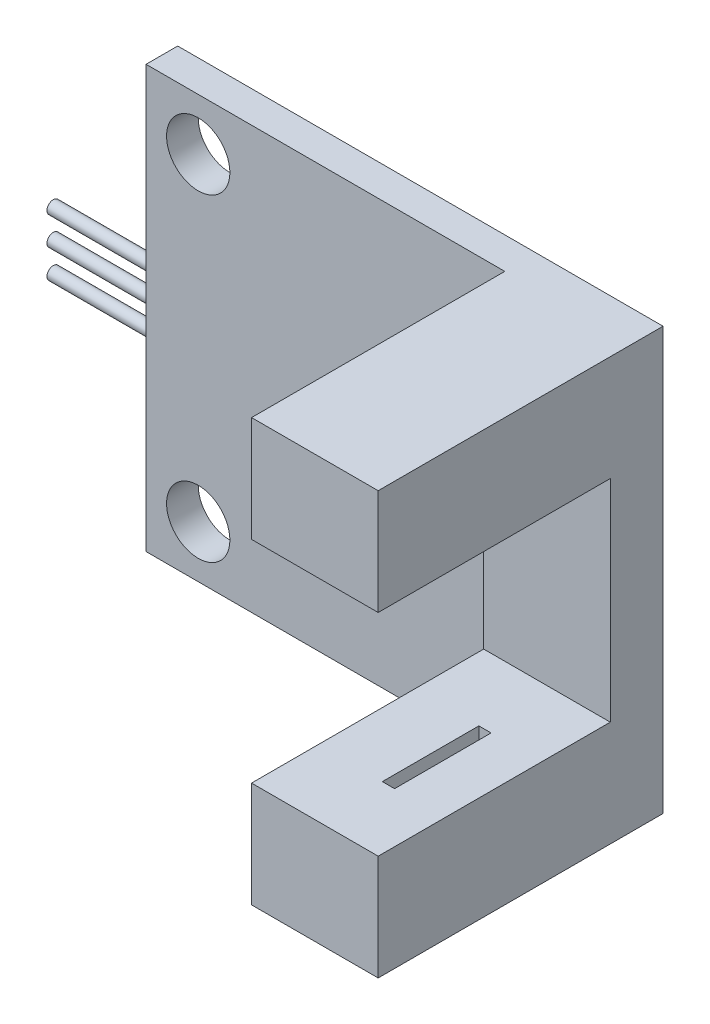
from build123d import *

# Parameters (mm, degrees)
SKETCH_1_W          = 23
SKETCH_1_H          = 20
EXTRUDE_1_DEPTH     = 1.5
SKETCH_2_W          = 6
SKETCH_2_H          = 20
EXTRUDE_2_DEPTH     = 12
SKETCH_3_W          = 6
SKETCH_3_H          = 10
CUT_EXTRUDE_1_DEPTH = 11
SKETCH_4_R          = 0.3
EXTRUDE_3_DEPTH     = 5
SKETCH_5_R          = 1.5
CUT_EXTRUDE_2_DEPTH = 7
SKETCH_6_W          = 0.579660534
SKETCH_6_H          = 4.573153075
CUT_EXTRUDE_3_DEPTH = 2


with BuildPart() as part:
    # 草图1 → 凸台-拉伸1 (new body)
    with BuildSketch(Plane.XY):
        Rectangle(SKETCH_1_W, SKETCH_1_H)
    extrude(amount=EXTRUDE_1_DEPTH)

    # 草图2 → 凸台-拉伸2 (add)
    with BuildSketch(Plane.XY.offset(1.5)):
        with Locations((8.5, 0)):
            Rectangle(SKETCH_2_W, SKETCH_2_H)
    extrude(amount=EXTRUDE_2_DEPTH)

    # 草图3 → 切除-拉伸1 (cut)
    with BuildSketch(Plane.XY.offset(13.5)):
        with Locations((8.5, 0)):
            Rectangle(SKETCH_3_W, SKETCH_3_H)
    extrude(amount=-CUT_EXTRUDE_1_DEPTH, mode=Mode.SUBTRACT)

    # 草图4 → 凸台-拉伸3 (add)
    with BuildSketch(Plane.ZY.offset(11.5)):
        with Locations((0.896688641, 1.343491603)):
            Circle(SKETCH_4_R)
        with Locations((0.896688641, 0)):
            Circle(SKETCH_4_R)
        with Locations((0.896688641, -1.361244933)):
            Circle(SKETCH_4_R)
    extrude(amount=EXTRUDE_3_DEPTH)

    # 草图5 → 切除-拉伸2 (cut)
    with BuildSketch(Plane.XY.offset(1.5)):
        with Locations((-9.028150669, -7.540646778)):
            Circle(SKETCH_5_R)
    cut_extrude_2 = extrude(amount=-CUT_EXTRUDE_2_DEPTH, mode=Mode.SUBTRACT)

    # 镜向1: 切除-拉伸2 across plane
    add(cut_extrude_2.mirror(Plane.ZX), mode=Mode.SUBTRACT)

    # 草图6 → 切除-拉伸3 (cut)
    with BuildSketch(Plane(origin=(0, -5, 0), x_dir=(1, 0, 0), z_dir=(0, 1, 0))):
        with Locations((8.828789431, -8.054724521)):
            Rectangle(SKETCH_6_W, SKETCH_6_H)
    cut_extrude_3 = extrude(amount=-CUT_EXTRUDE_3_DEPTH, mode=Mode.SUBTRACT)

    # 镜向2: 切除-拉伸3 across plane
    add(cut_extrude_3.mirror(Plane.ZX), mode=Mode.SUBTRACT)


solid = part.part
